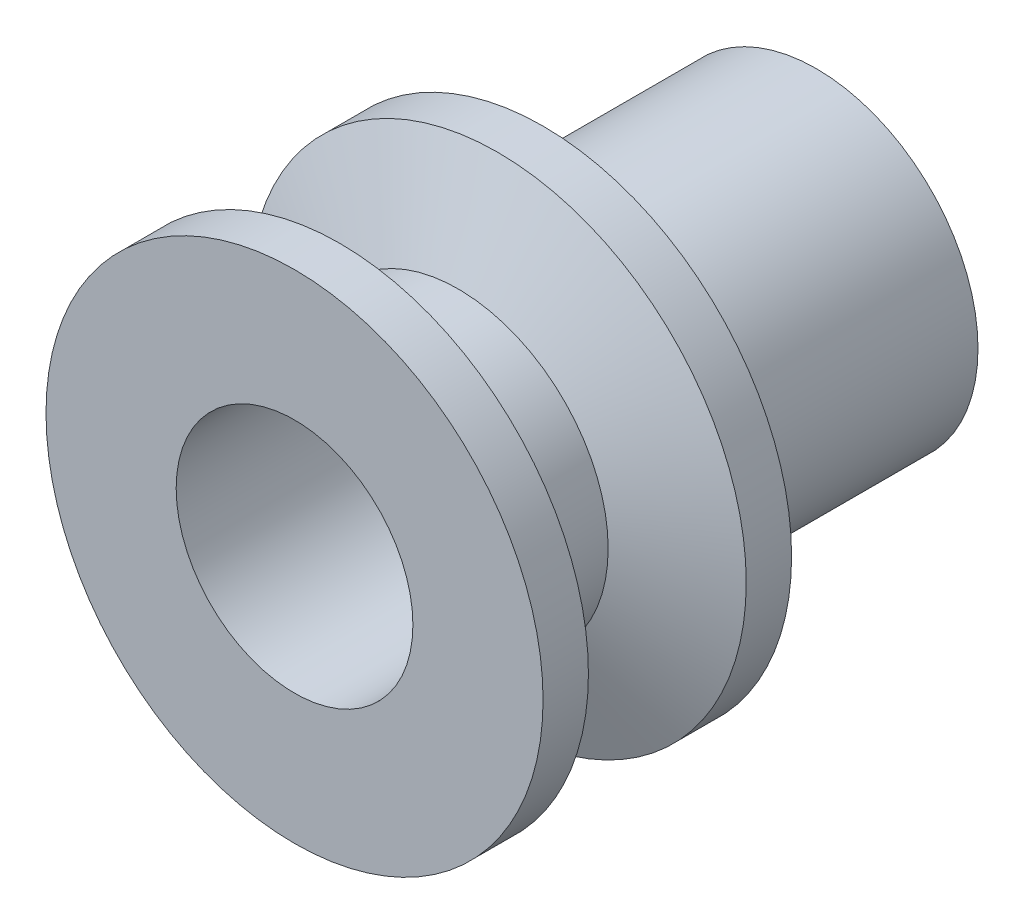
from build123d import *

# Parameters (mm, degrees)
CROQUIS7_R            = 3.175
CORTAR_EXTRUIR2_DEPTH = 21


with BuildPart() as part:
    # Croquis2 → Revolución2 (revolve)
    with BuildSketch(Plane(origin=(0, 0, 0), x_dir=(1, 0, 0), z_dir=(0, 1, 0))):
        Polygon((20, 0), (20, 3.65), (12.0625, 6.825), (12.0625, 13.175), (20, 16.35), (20, 20), (13, 20), (13, 42), (9.525, 42), (9.525, 0), align=None)
    revolve(axis=Axis((0, 0, 0), (0, 0, -1)))

    # Croquis7 → Cortar-Extruir2 (cut, through all)
    with BuildSketch(Plane(origin=(0, 0, 0), x_dir=(1, 0, 0), z_dir=(0, 1, 0))):
        with Locations((0, 32)):
            Circle(CROQUIS7_R)
    extrude(amount=-CORTAR_EXTRUIR2_DEPTH, mode=Mode.SUBTRACT)


solid = part.part
